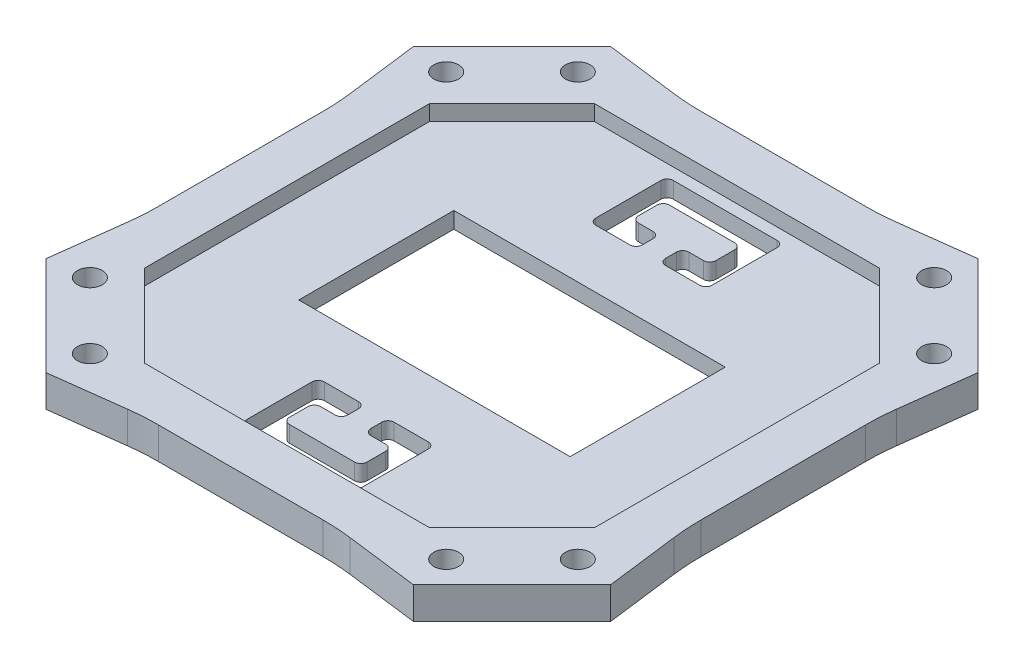
from build123d import *

# Parameters (mm, degrees)
SKETCH1_R           = 1.6
BOSS_EXTRUDE1_DEPTH = 4.1
CUT_EXTRUDE1_DEPTH  = 2
FILLET2_R           = 30
CUT_EXTRUDE4_DEPTH  = 52.538200475
SKETCH7_W           = 35
SKETCH7_H           = 20
CUT_EXTRUDE5_DEPTH  = 52.538200475


with BuildPart() as part:
    # Sketch1 → Boss-Extrude1 (new body)
    with BuildSketch(Plane(origin=(0, 0, 0), x_dir=(1, 0, 0), z_dir=(0, 1, 0))):
        Polygon((-12.5, 35), (12.5, 35), (23.684823703, 36.412745764), (36.412745764, 23.684823703), (35, 12.5), (35, -12.5), (36.412745764, -23.684823703), (23.684823703, -36.412745764), (12.5, -35), (-12.5, -35), (-23.684823703, -36.412745764), (-36.412745764, -23.684823703), (-35, -12.5), (-35, 12.5), (-36.412745764, 23.684823703), (-23.684823703, 36.412745764), align=None)
        with Locations((22.977716922, 31.462998296)):
            Circle(SKETCH1_R, mode=Mode.SUBTRACT)
        with Locations((31.462998296, 22.977716922)):
            Circle(SKETCH1_R, mode=Mode.SUBTRACT)
        with Locations((31.462998296, -22.977716922)):
            Circle(SKETCH1_R, mode=Mode.SUBTRACT)
        with Locations((22.977716922, -31.462998296)):
            Circle(SKETCH1_R, mode=Mode.SUBTRACT)
        with Locations((-22.977716922, -31.462998296)):
            Circle(SKETCH1_R, mode=Mode.SUBTRACT)
        with Locations((-31.462998296, -22.977716922)):
            Circle(SKETCH1_R, mode=Mode.SUBTRACT)
        with Locations((-31.462998296, 22.977716922)):
            Circle(SKETCH1_R, mode=Mode.SUBTRACT)
        with Locations((-22.977716922, 31.462998296)):
            Circle(SKETCH1_R, mode=Mode.SUBTRACT)
    extrude(amount=BOSS_EXTRUDE1_DEPTH)

    # Sketch2 → Cut-Extrude1 (cut)
    with BuildSketch(Plane(origin=(0, 4.1, 0), x_dir=(1, 0, 0), z_dir=(0, 1, 0))):
        Polygon((18.369647406, 29), (-18.369647406, 29), (-29, 18.369647406), (-29, -18.369647406), (-18.369647406, -29), (18.369647406, -29), (29, -18.369647406), (29, 18.369647406), align=None)
    extrude(amount=-CUT_EXTRUDE1_DEPTH, mode=Mode.SUBTRACT)

    # Fillet2
    fillet2_edges = [part.edges().sort_by_distance(p)[0] for p in [
        (-35, 2.05, 12.5),
        (-35, 2.05, -12.5),
        (-12.5, 2.05, -35),
        (12.5, 2.05, -35),
        (35, 2.05, -12.5),
        (35, 2.05, 12.5),
        (12.5, 2.05, 35),
        (-12.5, 2.05, 35),
    ]]
    fillet(fillet2_edges, radius=FILLET2_R)

    # Sketch6 → Cut-Extrude4 (cut, through all)
    with BuildSketch(Plane(origin=(0, 2.1, 0), x_dir=(1, 0, 0), z_dir=(0, 1, 0))):
        with BuildLine():
            Line((-1.5, 19.7), (-1.5, 18.3))
            ThreePointArc((-1.5, 18.3), (-1.734314575, 17.734314575), (-2.3, 17.5))
            Line((-2.3, 17.5), (-6.7, 17.5))
            ThreePointArc((-6.7, 17.5), (-7.265685425, 17.734314575), (-7.5, 18.3))
            Line((-7.5, 18.3), (-7.5, 26.7))
            ThreePointArc((-7.5, 26.7), (-7.265685425, 27.265685425), (-6.7, 27.5))
            Line((-6.7, 27.5), (6.7, 27.5))
            ThreePointArc((6.7, 27.5), (7.265685425, 27.265685425), (7.5, 26.7))
            Line((7.5, 26.7), (7.5, 18.3))
            ThreePointArc((7.5, 18.3), (7.265685425, 17.734314575), (6.7, 17.5))
            Line((6.7, 17.5), (2.3, 17.5))
            ThreePointArc((2.3, 17.5), (1.734314575, 17.734314575), (1.5, 18.3))
            Line((1.5, 18.3), (1.5, 19.7))
            ThreePointArc((1.5, 19.7), (1.734314575, 20.265685425), (2.3, 20.5))
            Line((2.3, 20.5), (4.2, 20.5))
            ThreePointArc((4.2, 20.5), (4.765685425, 20.734314575), (5, 21.3))
            Line((5, 21.3), (5, 23.7))
            ThreePointArc((5, 23.7), (4.765685425, 24.265685425), (4.2, 24.5))
            Line((4.2, 24.5), (-4.2, 24.5))
            ThreePointArc((-4.2, 24.5), (-4.765685425, 24.265685425), (-5, 23.7))
            Line((-5, 23.7), (-5, 21.3))
            ThreePointArc((-5, 21.3), (-4.765685425, 20.734314575), (-4.2, 20.5))
            Line((-4.2, 20.5), (-2.3, 20.5))
            ThreePointArc((-2.3, 20.5), (-1.734314575, 20.265685425), (-1.5, 19.7))
        make_face()
        with BuildLine():
            Line((-1.5, -19.7), (-1.5, -18.3))
            ThreePointArc((-1.5, -18.3), (-1.734314575, -17.734314575), (-2.3, -17.5))
            Line((-2.3, -17.5), (-6.7, -17.5))
            ThreePointArc((-6.7, -17.5), (-7.265685425, -17.734314575), (-7.5, -18.3))
            Line((-7.5, -18.3), (-7.5, -26.7))
            ThreePointArc((-7.5, -26.7), (-7.265685425, -27.265685425), (-6.7, -27.5))
            Line((-6.7, -27.5), (6.7, -27.5))
            ThreePointArc((6.7, -27.5), (7.265685425, -27.265685425), (7.5, -26.7))
            Line((7.5, -26.7), (7.5, -18.3))
            ThreePointArc((7.5, -18.3), (7.265685425, -17.734314575), (6.7, -17.5))
            Line((6.7, -17.5), (2.3, -17.5))
            ThreePointArc((2.3, -17.5), (1.734314575, -17.734314575), (1.5, -18.3))
            Line((1.5, -18.3), (1.5, -19.7))
            ThreePointArc((1.5, -19.7), (1.734314575, -20.265685425), (2.3, -20.5))
            Line((2.3, -20.5), (4.2, -20.5))
            ThreePointArc((4.2, -20.5), (4.765685425, -20.734314575), (5, -21.3))
            Line((5, -21.3), (5, -23.7))
            ThreePointArc((5, -23.7), (4.765685425, -24.265685425), (4.2, -24.5))
            Line((4.2, -24.5), (-4.2, -24.5))
            ThreePointArc((-4.2, -24.5), (-4.765685425, -24.265685425), (-5, -23.7))
            Line((-5, -23.7), (-5, -21.3))
            ThreePointArc((-5, -21.3), (-4.765685425, -20.734314575), (-4.2, -20.5))
            Line((-4.2, -20.5), (-2.3, -20.5))
            ThreePointArc((-2.3, -20.5), (-1.734314575, -20.265685425), (-1.5, -19.7))
        make_face()
    extrude(amount=-CUT_EXTRUDE4_DEPTH, mode=Mode.SUBTRACT)

    # Sketch7 → Cut-Extrude5 (cut, through all)
    with BuildSketch(Plane(origin=(0, 2.1, 0), x_dir=(1, 0, 0), z_dir=(0, 1, 0))):
        Rectangle(SKETCH7_W, SKETCH7_H)
    extrude(amount=-CUT_EXTRUDE5_DEPTH, mode=Mode.SUBTRACT)


solid = part.part
